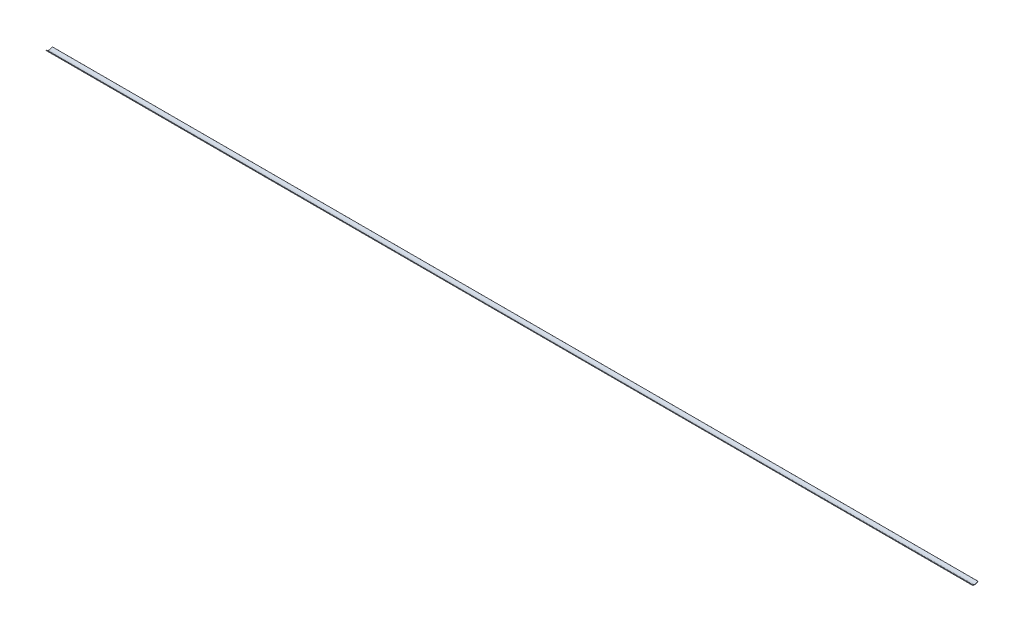
from build123d import *

# Parameters (mm, degrees)
BOSS_EXTRUDE7_DEPTH = 800


with BuildPart() as part:
    # Sketch7 → Boss-Extrude7 (new body)
    with BuildSketch(Plane(origin=(0, 0, 0), x_dir=(0, 0, -1), z_dir=(1, 0, 0))):
        with BuildLine():
            Line((2.727993364, 26.945293334), (2.497196154, 27.154925683))
            ThreePointArc((2.497196154, 27.154925683), (-0.045784316, 26.049902517), (-2.557836818, 27.223537083))
            Line((-2.557836818, 27.223537083), (-2.798892732, 27.025668774))
            ThreePointArc((-2.798892732, 27.025668774), (-0.053588552, 25.738191345), (2.727993364, 26.945293334))
        make_face()
    extrude(amount=BOSS_EXTRUDE7_DEPTH)


solid = part.part
